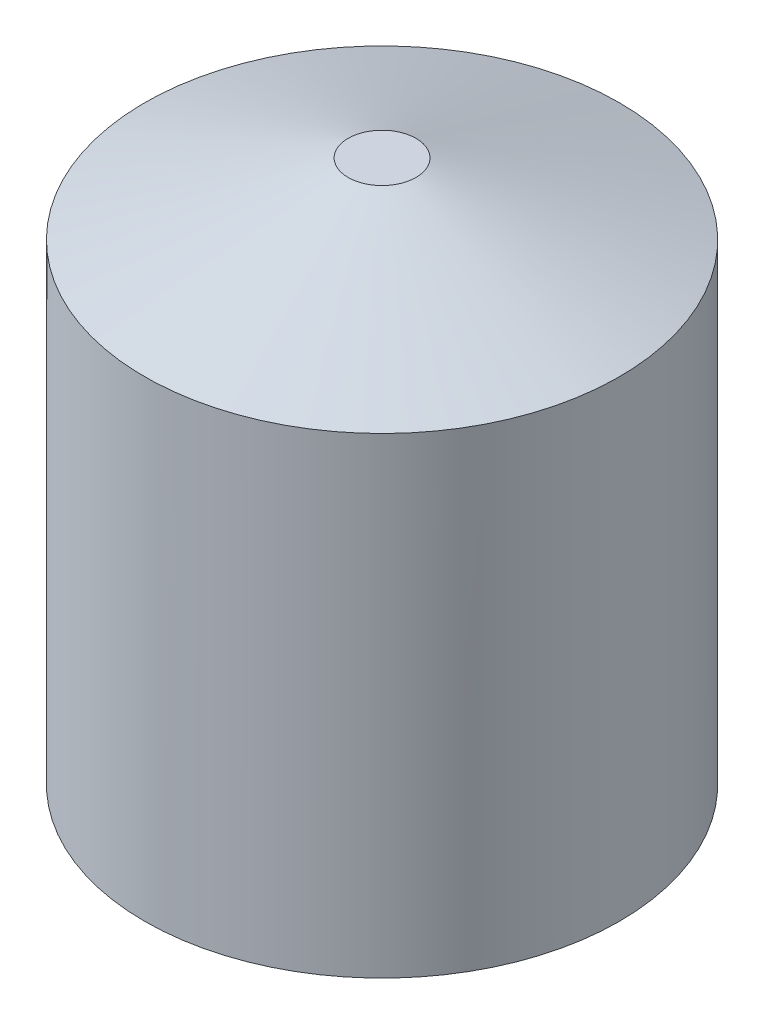
from build123d import *

# Parameters (mm, degrees)
SKETCH1_R           = 1400
BOSS_EXTRUDE1_DEPTH = 3200


with BuildPart() as part:
    # Sketch1 → Boss-Extrude1 (new body)
    with BuildSketch(Plane(origin=(0, 0, 0), x_dir=(1, 0, 0), z_dir=(0, 1, 0))):
        Circle(SKETCH1_R)
    extrude(amount=BOSS_EXTRUDE1_DEPTH)

    # Sketch2 → Cut-Revolve2 (revolve, cut)
    with BuildSketch(Plane.XY):
        Polygon((200, 3200), (1990.74236953, 2576.311431408), (1990.74236953, 3200), align=None)
    revolve(axis=Axis((0, 4385.8596743, 0), (0, -1, 0)), mode=Mode.SUBTRACT)


solid = part.part
